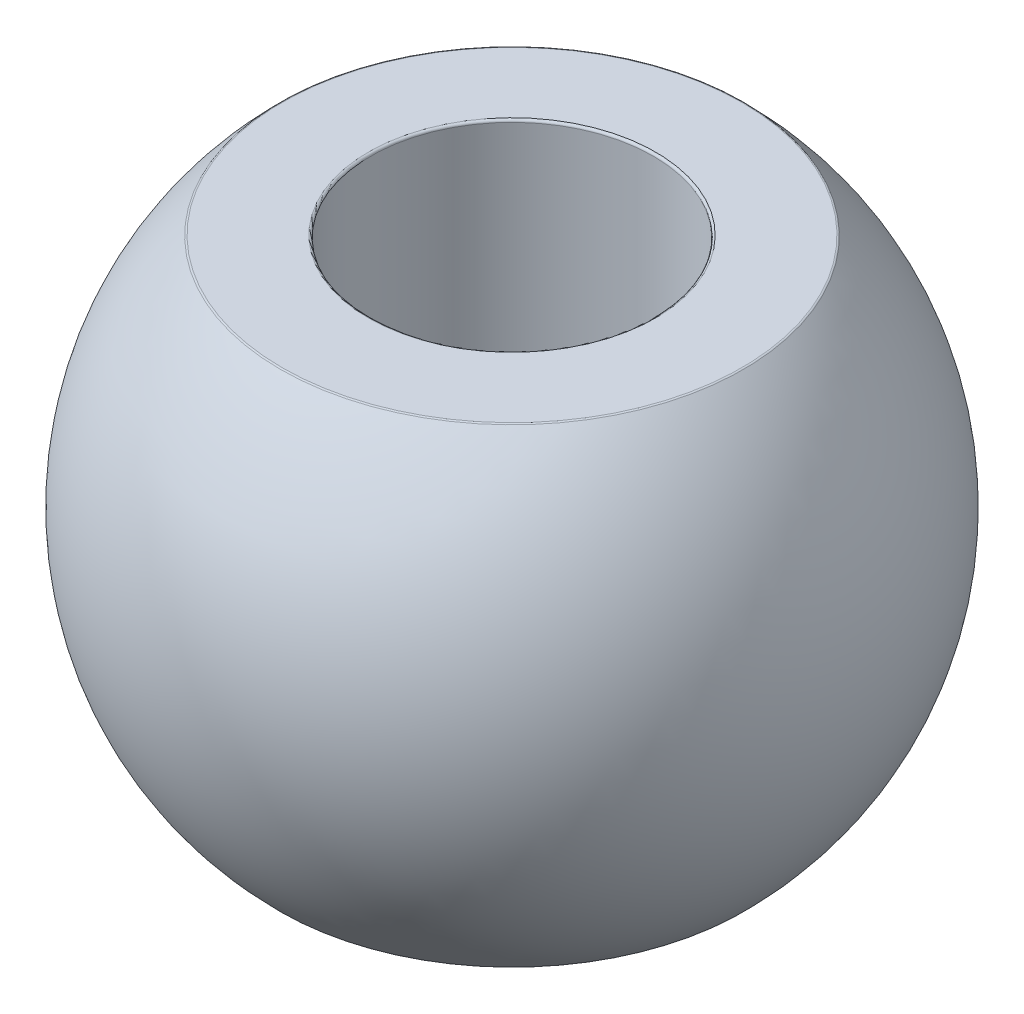
from build123d import *

# Parameters (mm, degrees)
FILLET1_R    = 0.1
SCALE1_SCALE = 0.25


with BuildPart() as part:
    # Sketch1 → Revolve1 (revolve)
    with BuildSketch(Plane.XY):
        with BuildLine():
            Line((6, -10), (6, 10))
            Line((6, 10), (9.797958971, 10))
            ThreePointArc((9.797958971, 10), (14, 0), (9.797958971, -10))
            Line((9.797958971, -10), (6, -10))
        make_face()
    revolve(axis=Axis((0, 0, 0), (0, 1, 0)))

    # Fillet1
    fillet1_edges = [part.edges().sort_by_distance(p)[0] for p in [
        (-9.797958971, -10, 0),
        (-9.797958971, 10, 0),
        (-6, 10, 0),
        (-6, -10, 0),
    ]]
    fillet(fillet1_edges, radius=FILLET1_R)


with BuildPart() as part_1:
    # Scale1: scaled about (-6e-09, 1.26e-07, 0)
    add(part.part.scale(SCALE1_SCALE).moved(Location((-4e-09, 9.4e-08, 0))))


solid = part_1.part
